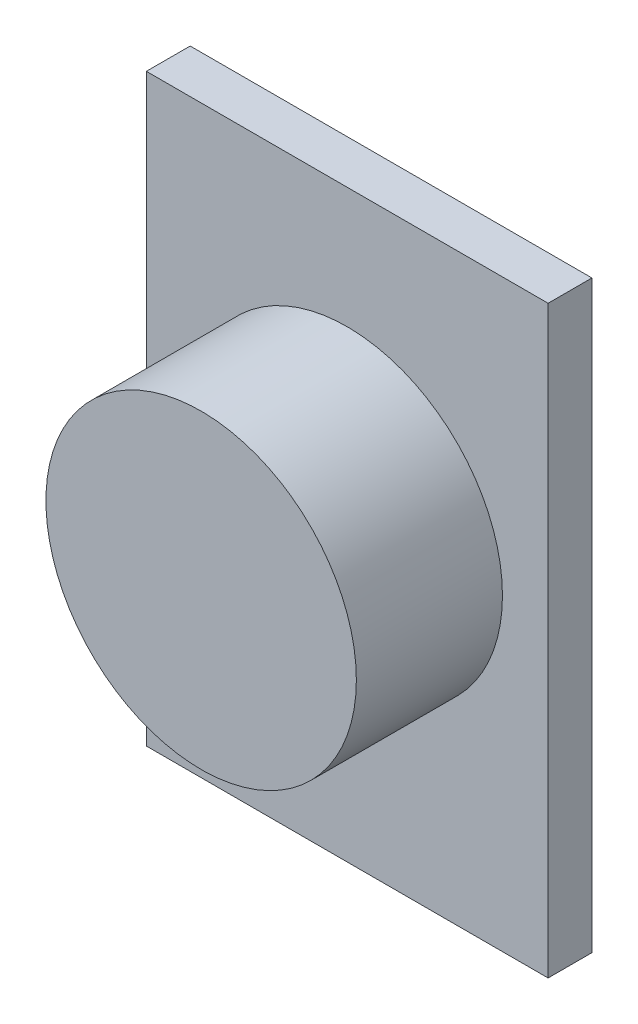
from build123d import *

# Parameters (mm, degrees)
SKETCH1_W           = 11
SKETCH1_H           = 16
BOSS_EXTRUDE1_DEPTH = 1.2
SKETCH2_R           = 4.25
BOSS_EXTRUDE2_DEPTH = 4


with BuildPart() as part:
    # Sketch1 → Boss-Extrude1 (new body)
    with BuildSketch(Plane.XY):
        Rectangle(SKETCH1_W, SKETCH1_H)
    extrude(amount=BOSS_EXTRUDE1_DEPTH)

    # Sketch2 → Boss-Extrude2 (add)
    with BuildSketch(Plane.XY.offset(1.2)):
        with Locations((0, 0.443544307)):
            Circle(SKETCH2_R)
    extrude(amount=BOSS_EXTRUDE2_DEPTH)


solid = part.part
